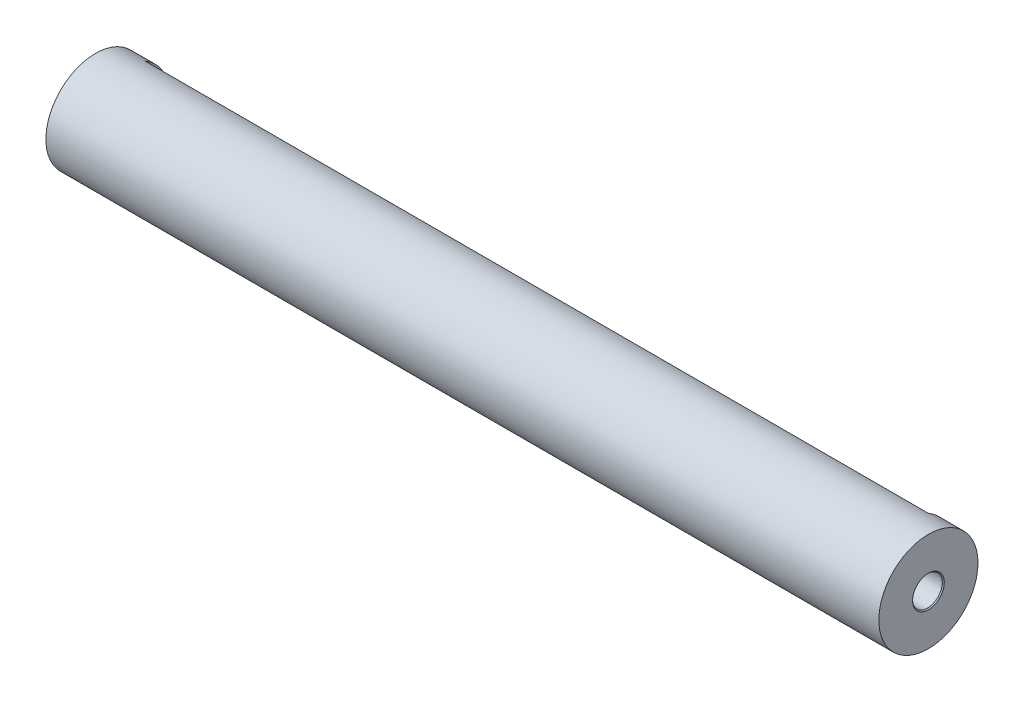
from build123d import *

# Parameters (mm, degrees)
SKETCH_1_R               = 5
EXTRUDE_1_DEPTH          = 84
SKETCH_6_W               = 79
SKETCH_6_H               = 8.752302232
CUT_EXTRUDE_1_DEPTH      = 6
CUT_EXTRUDE_1_DEPTH_BACK = 6


with BuildPart() as part:
    # Эскиз1 → Бобышка-Вытянуть1 (new body)
    with BuildSketch(Plane(origin=(0, 0, 0), x_dir=(0, 0, -1), z_dir=(1, 0, 0))):
        Circle(SKETCH_1_R)
    extrude(amount=EXTRUDE_1_DEPTH)

    # Эскиз2 → Отверстие обработанное метчиком M31 (revolve, cut)
    with BuildSketch(Plane.ZX):
        Polygon((0, 0), (0, 12.751075774), (1.25, 12), (1.25, 9), (1.5, 9), (1.5, 0.1), (1.6, 0), align=None)
    revolve(axis=Axis((-6.35, 0, 0), (1, 0, 0)), mode=Mode.SUBTRACT)

    # Эскиз4 → Отверстие обработанное метчиком M32 (revolve, cut)
    with BuildSketch(Plane(origin=(84, 0, 0), x_dir=(0, 0, -1), z_dir=(0, 1, 0))):
        Polygon((0, 0), (0, 12.751075774), (1.25, 12), (1.25, 9), (1.5, 9), (1.5, 0.1), (1.6, 0), align=None)
    revolve(axis=Axis((90.35, 0, 0), (-1, 0, 0)), mode=Mode.SUBTRACT)

    # Эскиз6 → Вырез-Вытянуть1 (cut, two sides)
    with BuildSketch(Plane(origin=(0, 0, 0), x_dir=(1, 0, 0), z_dir=(0, 1, 0))) as cut_extrude_1_sk:
        with Locations((42, 6.876151116)):
            Rectangle(SKETCH_6_W, SKETCH_6_H)
    extrude(amount=CUT_EXTRUDE_1_DEPTH, mode=Mode.SUBTRACT)
    extrude(cut_extrude_1_sk.sketch, amount=-CUT_EXTRUDE_1_DEPTH_BACK, mode=Mode.SUBTRACT)


solid = part.part
